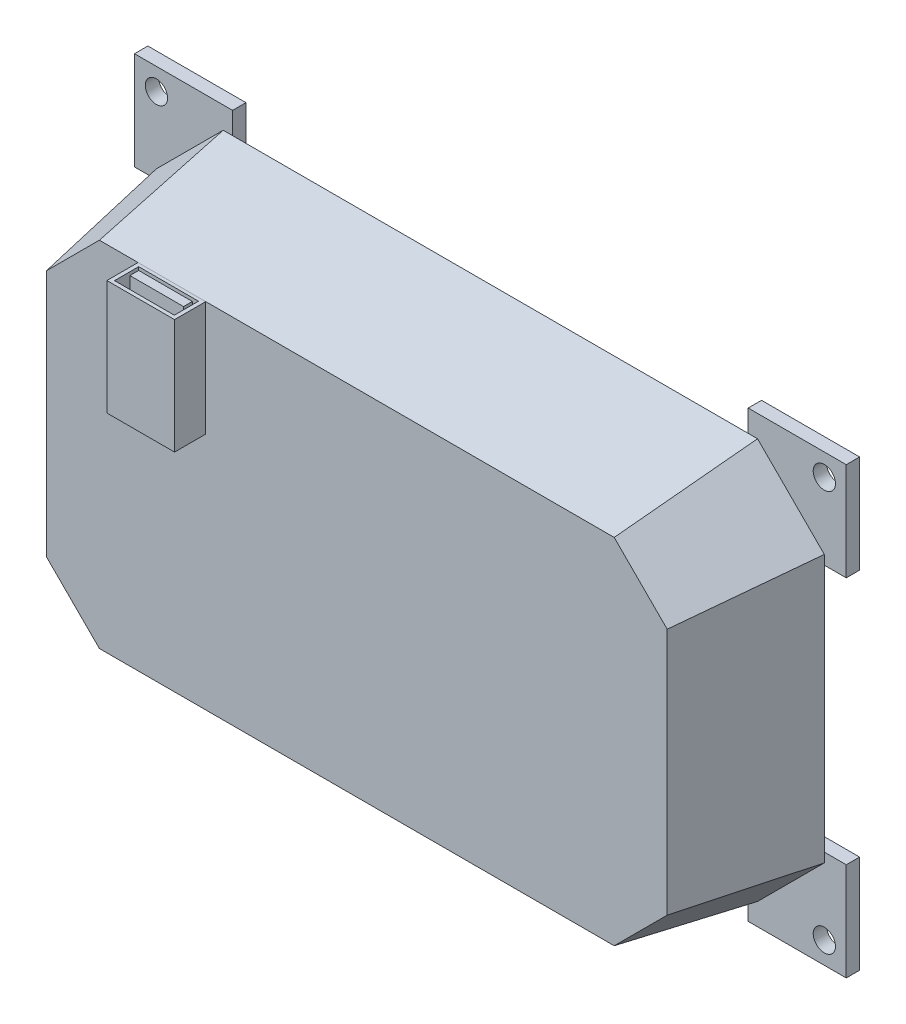
from build123d import *

# Parameters (mm, degrees)
BOSS_EXTRUDE1_DEPTH      = 30
BOSS_EXTRUDE1_TAPER      = 10
SHELL1_T                 = -5
SKETCH6_W                = 15.197518051
SKETCH6_H                = 25.772318446
BOSS_EXTRUDE4_DEPTH      = 7
SKETCH7_W                = 13.433844537
SKETCH7_H                = 5.428745395
SKETCH7_W_2              = 12.053655029
SKETCH7_H_2              = 1.978271627
CUT_EXTRUDE2_DEPTH       = 17
BOSS_EXTRUDE6_DEPTH      = 3
MIRROR9_COPY_1_DEPTH     = 3
CUT_EXTRUDE4_START       = -4
SKETCH12_R               = 2.5
CUT_EXTRUDE4_DEPTH       = 42
MIRROR11_START           = -4
MIRROR11_COPY_1_SKETCH_R = 2.5
MIRROR11_COPY_1_DEPTH    = 42


with BuildPart() as part:
    # Sketch1 → Boss-Extrude1 (new body)
    with BuildSketch(Plane.XY):
        Polygon((-100, 10.531931481), (-100, -49.468068519), (-85, -64.468068519), (35, -64.468068519), (50, -49.468068519), (50, 10.531931481), (35, 25.531931481), (-85, 25.531931481), align=None)
    extrude(amount=BOSS_EXTRUDE1_DEPTH, taper=BOSS_EXTRUDE1_TAPER)

    # Shell1
    shell1_openings = [part.faces().sort_by_distance(p)[0] for p in [
        (-25, -19.468068519, 0),
    ]]
    offset(amount=SHELL1_T, openings=shell1_openings, kind=Kind.INTERSECTION)

    # Sketch6 → Boss-Extrude4 (add)
    with BuildSketch(Plane.XY.offset(30)):
        with Locations((-66.525501272, 7.355962837)):
            Rectangle(SKETCH6_W, SKETCH6_H)
    extrude(amount=BOSS_EXTRUDE4_DEPTH)

    # Sketch7 → Cut-Extrude2 (cut)
    with BuildSketch(Plane(origin=(0, 20.24212206, 0), x_dir=(1, 0, 0), z_dir=(0, 1, 0))):
        with Locations((-66.527599538, -33.454113167)):
            Rectangle(SKETCH7_W, SKETCH7_H)
        with Locations((-66.481593222, -32.464977353)):
            Rectangle(SKETCH7_W_2, SKETCH7_H_2, mode=Mode.SUBTRACT)
    extrude(amount=-CUT_EXTRUDE2_DEPTH, mode=Mode.SUBTRACT)

    # Sketch11 → Boss-Extrude6 (add)
    with BuildSketch(Plane(origin=(0, 0, 0), x_dir=(-1, 0, 0), z_dir=(0, 0, -1))):
        Polygon((94.922866941, -47.365051148), (82.896982629, -59.390935459), (82.896982629, -69.390935459), (104.922866941, -69.390935459), (104.922866941, -47.365051148), align=None)
    boss_extrude6 = extrude(amount=BOSS_EXTRUDE6_DEPTH)

    # Mirror8: Boss-Extrude6 across plane
    add(boss_extrude6.mirror(Plane(origin=(-25, 0, 0), x_dir=(0, 0, 1), z_dir=(1, 0, 0))))

    # Mirror9: Boss-Extrude6 across plane
    add(boss_extrude6.mirror(Plane.ZX.offset(-19.468068519)))

    # Mirror9 copy 1 sketch → Mirror9 copy 1 (add)
    with BuildSketch(Plane(origin=(-50, -38.936137038, 0), x_dir=(1, 0, 0), z_dir=(0, 0, -1))):
        Polygon((94.922866941, -47.365051148), (82.896982629, -59.390935459), (82.896982629, -69.390935459), (104.922866941, -69.390935459), (104.922866941, -47.365051148), align=None)
    extrude(amount=MIRROR9_COPY_1_DEPTH)

    # Sketch12 → Cut-Extrude4 (cut)
    with BuildSketch(Plane.XY.offset(CUT_EXTRUDE4_START)):
        with Locations((-100, -64.468068519)):
            Circle(SKETCH12_R)
    cut_extrude4 = extrude(amount=CUT_EXTRUDE4_DEPTH, mode=Mode.SUBTRACT)

    # Mirror10: Cut-Extrude4 across plane
    add(cut_extrude4.mirror(Plane(origin=(-25, 0, 0), x_dir=(0, 0, 1), z_dir=(1, 0, 0))), mode=Mode.SUBTRACT)

    # Mirror11: Cut-Extrude4 across plane
    add(cut_extrude4.mirror(Plane.ZX.offset(-19.468068519)), mode=Mode.SUBTRACT)

    # Mirror11 copy 1 sketch → Mirror11 copy 1 (cut)
    with BuildSketch(Plane(origin=(-50, -38.936137038, 0), x_dir=(-1, 0, 0), z_dir=(0, 0, 1)).offset(MIRROR11_START)):
        with Locations((-100, -64.468068519)):
            Circle(MIRROR11_COPY_1_SKETCH_R)
    extrude(amount=MIRROR11_COPY_1_DEPTH, mode=Mode.SUBTRACT)


solid = part.part
